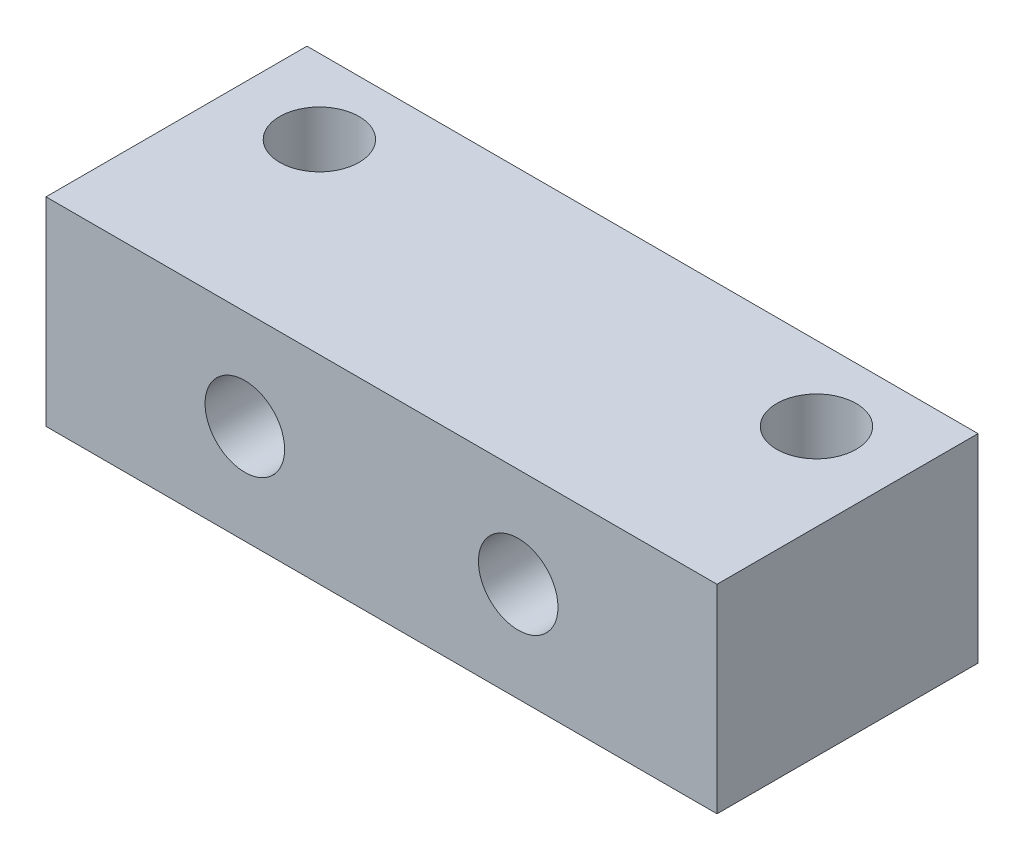
from build123d import *

# Parameters (mm, degrees)
SKETCH1_W               = 27
SKETCH1_H               = 6
SKETCH1_R               = 1.6
BOSS_EXTRUDE1_DEPTH     = 8
SKETCH3_W               = 27
SKETCH3_H               = 8
BOSS_EXTRUDE2_DEPTH     = 4.5
SKETCH2_R               = 1.6
CUT_EXTRUDE1_DEPTH      = 8.5
CUT_EXTRUDE1_DEPTH_BACK = 4


with BuildPart() as part:
    # Sketch1 → Boss-Extrude1 (new body)
    with BuildSketch(Plane(origin=(0, 0, 0), x_dir=(1, 0, 0), z_dir=(0, 1, 0))):
        with Locations((10, 0)):
            Rectangle(SKETCH1_W, SKETCH1_H)
        Circle(SKETCH1_R, mode=Mode.SUBTRACT)
        with Locations((20, 0)):
            Circle(SKETCH1_R, mode=Mode.SUBTRACT)
    extrude(amount=BOSS_EXTRUDE1_DEPTH)

    # Sketch3 → Boss-Extrude2 (add)
    with BuildSketch(Plane.XY.offset(3)):
        with Locations((10, 4)):
            Rectangle(SKETCH3_W, SKETCH3_H)
    extrude(amount=BOSS_EXTRUDE2_DEPTH)

    # Sketch2 → Cut-Extrude1 (cut, two sides)
    with BuildSketch(Plane.XY) as cut_extrude1_sk:
        with Locations((4.5, 4)):
            Circle(SKETCH2_R)
        with Locations((15.5, 4)):
            Circle(SKETCH2_R)
    extrude(amount=CUT_EXTRUDE1_DEPTH, mode=Mode.SUBTRACT)
    extrude(cut_extrude1_sk.sketch, amount=-CUT_EXTRUDE1_DEPTH_BACK, mode=Mode.SUBTRACT)


solid = part.part
